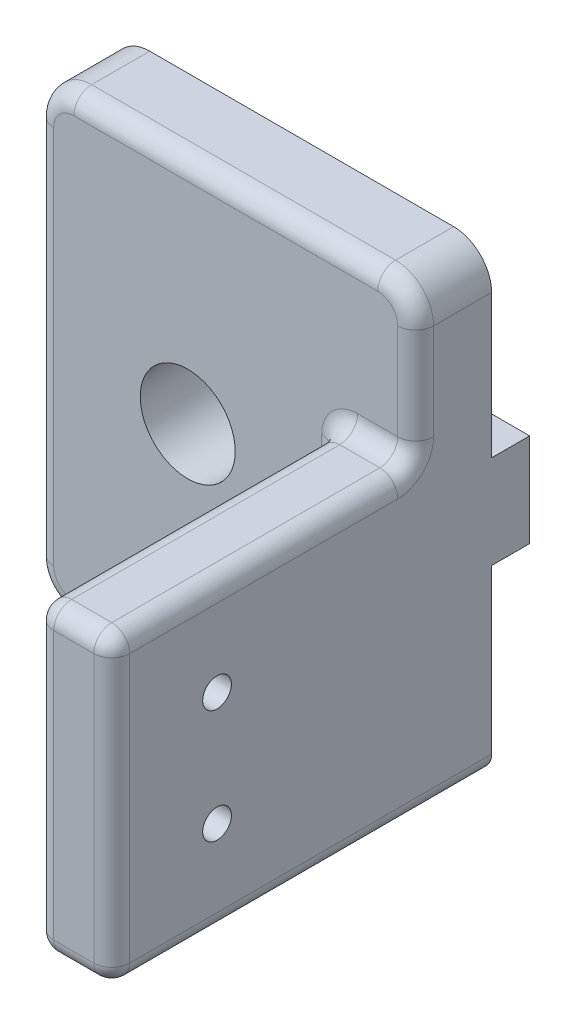
from build123d import *

# Parameters (mm, degrees)
SKETCH1_W           = 31.75
SKETCH1_H           = 38.1
BOSS_EXTRUDE1_DEPTH = 6.35
SKETCH2_W           = 6.35
SKETCH2_H           = 25.4
BOSS_EXTRUDE2_DEPTH = 25.4
SKETCH3_R           = 1.2
CUT_EXTRUDE1_DEPTH  = 7.35
SKETCH4_R           = 3.96875
CUT_EXTRUDE2_DEPTH  = 7.35
SKETCH5_W           = 3.18
SKETCH5_H           = 7.8
BOSS_EXTRUDE3_DEPTH = 31.75
FILLET1_R           = 3.175
FILLET2_R           = 1.5
CUT_EXTRUDE3_DEPTH  = 4.18
SKETCH7_R           = 5.866318131
CUT_EXTRUDE4_DEPTH  = 3.18


with BuildPart() as part:
    # Sketch1 → Boss-Extrude1 (new body)
    with BuildSketch(Plane.XY):
        with Locations((15.875, 19.05)):
            Rectangle(SKETCH1_W, SKETCH1_H)
    extrude(amount=BOSS_EXTRUDE1_DEPTH)

    # Sketch2 → Boss-Extrude2 (add)
    with BuildSketch(Plane.XY.offset(6.35)):
        with Locations((28.575, 12.7)):
            Rectangle(SKETCH2_W, SKETCH2_H)
    extrude(amount=BOSS_EXTRUDE2_DEPTH)

    # Sketch3 → Cut-Extrude1 (cut, through all)
    with BuildSketch(Plane.ZY.offset(-25.4)):
        with Locations((22.95, 17.45)):
            Circle(SKETCH3_R)
        with Locations((22.95, 7.95)):
            Circle(SKETCH3_R)
    extrude(amount=-CUT_EXTRUDE1_DEPTH, mode=Mode.SUBTRACT)

    # Sketch4 → Cut-Extrude2 (cut, through all)
    with BuildSketch(Plane.XY.offset(6.35)):
        with Locations((12.7, 19.05)):
            Circle(SKETCH4_R)
    extrude(amount=-CUT_EXTRUDE2_DEPTH, mode=Mode.SUBTRACT)

    # Sketch5 → Boss-Extrude3 (add)
    with BuildSketch(Plane.ZY):
        with Locations((-1.59, 19.05)):
            Rectangle(SKETCH5_W, SKETCH5_H)
    extrude(amount=-BOSS_EXTRUDE3_DEPTH)

    # Fillet1
    fillet1_edges = [part.edges().sort_by_distance(p)[0] for p in [
        (0, 0, 3.175),
        (0, 38.1, 3.175),
        (31.75, 38.1, 3.175),
    ]]
    fillet(fillet1_edges, radius=FILLET1_R)

    # Fillet2
    fillet2_edges = [part.edges().sort_by_distance(p)[0] for p in [
        (31.75, 30.1625, 6.35),
        (28.575, 0, 31.75),
        (25.4, 0, 19.05),
        (28.575, 25.4, 6.35),
        (31.75, 25.4, 19.05),
        (25.4, 12.7, 31.75),
        (25.4, 25.4, 19.05),
        (31.75, 12.7, 31.75),
        (28.575, 25.4, 31.75),
        (25.4, 12.7, 6.35),
        (15.875, 38.1, 6.35),
        (14.2875, 0, 6.35),
        (0, 19.05, 6.35),
        (0.92993597, 0.92993597, 6.35),
        (0.92993597, 37.17006403, 6.35),
        (30.82006403, 37.17006403, 6.35),
        (31.75, 0, 15.875),
    ]]
    fillet(fillet2_edges, radius=FILLET2_R)

    # Sketch6 → Cut-Extrude3 (cut, through all)
    with BuildSketch(Plane.XY):
        with BuildLine():
            Line((13.435511089, 22.95), (11.964488911, 22.95))
            ThreePointArc((11.964488911, 22.95), (8.73125, 19.05), (11.964488911, 15.15))
            Line((11.964488911, 15.15), (13.435511089, 15.15))
            ThreePointArc((13.435511089, 15.15), (16.66875, 19.05), (13.435511089, 22.95))
        make_face()
    extrude(amount=-CUT_EXTRUDE3_DEPTH, mode=Mode.SUBTRACT)

    # Sketch7 → Cut-Extrude4 (cut)
    with BuildSketch(Plane(origin=(0, 0, 0), x_dir=(-1, 0, 0), z_dir=(0, 0, -1))):
        with Locations((-12.7, 19.05)):
            Circle(SKETCH7_R)
    extrude(amount=CUT_EXTRUDE4_DEPTH, mode=Mode.SUBTRACT)


solid = part.part
